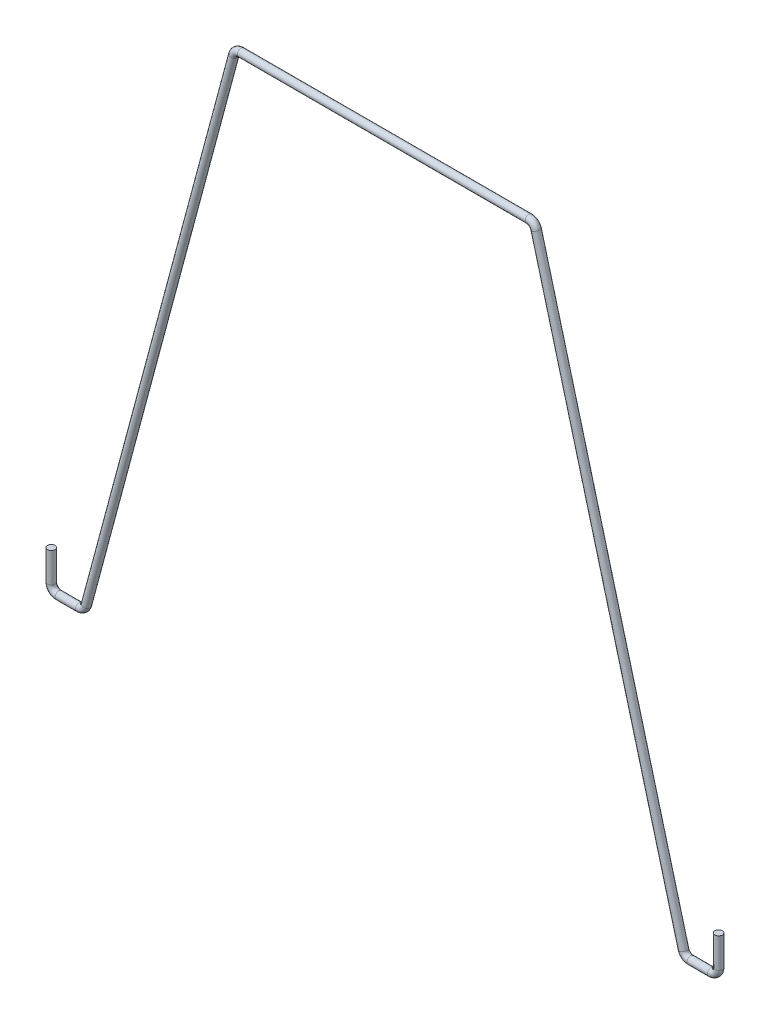
from build123d import *

# Parameters (mm, degrees)
SWEEP1_PROFILE_R = 0.254


with BuildPart() as part:
    # Sweep1: sweep along a path in Sketch1
    with BuildLine(Plane.XY) as sweep1_path:
        Line((-22.654864232, -35.56), (-22.654864232, -37.592))
        ThreePointArc((-22.654864232, -37.592), (-22.506074476, -37.951210245), (-22.146864232, -38.1))
        Line((-22.146864232, -38.1), (-20.758666342, -38.1))
        ThreePointArc((-20.758666342, -38.1), (-20.449415536, -37.995023497), (-20.267976022, -37.723480075))
        Line((-20.267976022, -37.723480075), (-10.26088821, -0.376519925))
        ThreePointArc((-10.26088821, -0.376519925), (-10.079448696, -0.104976503), (-9.77019789, 0))
        Line((-9.77019789, 0), (9.77019789, 0))
        ThreePointArc((9.77019789, 0), (10.079448696, -0.104976503), (10.26088821, -0.376519925))
        Line((10.26088821, -0.376519925), (20.267976022, -37.723480075))
        ThreePointArc((20.267976022, -37.723480075), (20.449415536, -37.995023497), (20.758666342, -38.1))
        Line((20.758666342, -38.1), (22.146864232, -38.1))
        ThreePointArc((22.146864232, -38.1), (22.506074476, -37.951210245), (22.654864232, -37.592))
        Line((22.654864232, -37.592), (22.654864232, -35.56))
    # Sweep1 profile (on start of the path) → Sweep1 (sweep)
    with BuildSketch(Plane(origin=(-22.654864232, -35.56, 0), x_dir=(-1, 0, 0), z_dir=(0, -1, 0))):
        Circle(SWEEP1_PROFILE_R)
    sweep(path=sweep1_path.line)


solid = part.part
